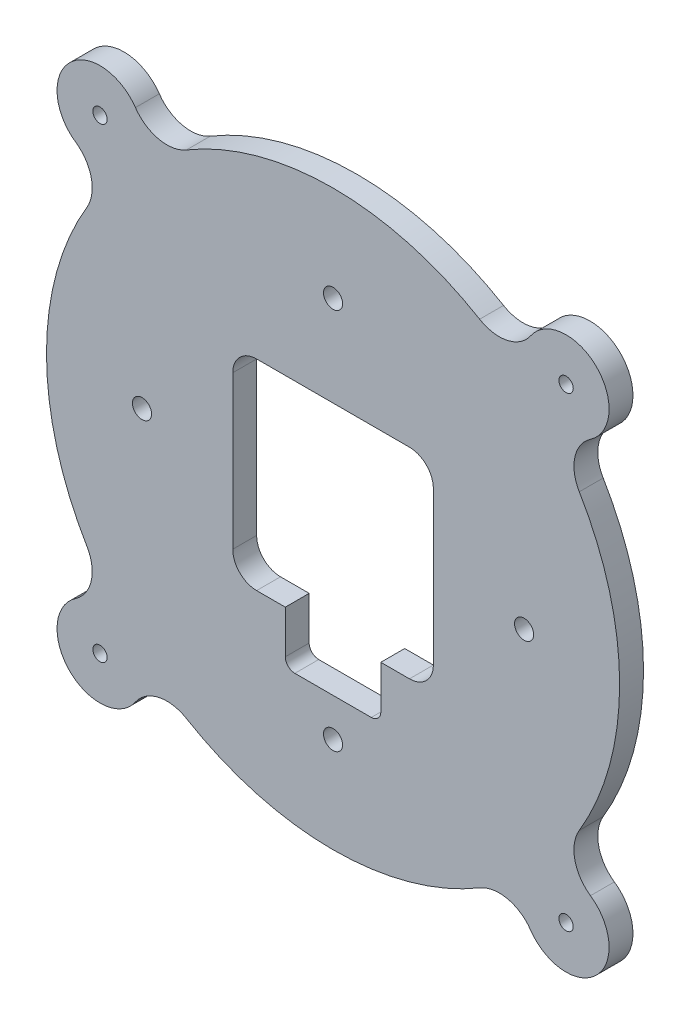
from build123d import *

# Parameters (mm, degrees)
SKETCH1_R             = 1.5
SKETCH1_R_2           = 2
BOSS_EXTRUDE1_DEPTH   = 5
BODY_MOVE_COPY1_ANGLE = 90


with BuildPart() as part:
    # Sketch1 → Boss-Extrude1 (new body)
    with BuildSketch(Plane(origin=(0, 0, 0), x_dir=(1, 0, 0), z_dir=(0, 1, 0))):
        with BuildLine():
            ThreePointArc((41.376602734, 53.892924716), (36.497232574, 50.613564399), (30.69404934, 51.554585976))
            ThreePointArc((30.69404934, 51.554585976), (0, 60), (-30.69404934, 51.554585976))
            ThreePointArc((-30.69404934, 51.554585976), (-36.497232574, 50.613564399), (-41.376602734, 53.892924716))
            ThreePointArc((-41.376602734, 53.892924716), (-55.154328933, 55.154328933), (-53.892924716, 41.376602734))
            ThreePointArc((-53.892924716, 41.376602734), (-50.613564399, 36.497232574), (-51.554585976, 30.69404934))
            ThreePointArc((-51.554585976, 30.69404934), (-60, 0), (-51.554585976, -30.69404934))
            ThreePointArc((-51.554585976, -30.69404934), (-50.613564399, -36.497232574), (-53.892924716, -41.376602734))
            ThreePointArc((-53.892924716, -41.376602734), (-55.154328933, -55.154328933), (-41.376602734, -53.892924716))
            ThreePointArc((-41.376602734, -53.892924716), (-36.497232574, -50.613564399), (-30.69404934, -51.554585976))
            ThreePointArc((-30.69404934, -51.554585976), (0, -60), (30.69404934, -51.554585976))
            ThreePointArc((30.69404934, -51.554585976), (36.497232574, -50.613564399), (41.376602734, -53.892924716))
            ThreePointArc((41.376602734, -53.892924716), (55.154328933, -55.154328933), (53.892924716, -41.376602734))
            ThreePointArc((53.892924716, -41.376602734), (50.613564399, -36.497232574), (51.554585976, -30.69404934))
            ThreePointArc((51.554585976, -30.69404934), (60, 0), (51.554585976, 30.69404934))
            ThreePointArc((51.554585976, 30.69404934), (50.613564399, 36.497232574), (53.892924716, 41.376602734))
            ThreePointArc((53.892924716, 41.376602734), (55.154328933, 55.154328933), (41.376602734, 53.892924716))
        make_face()
        with Locations((-48.790367902, -48.790367902)):
            Circle(SKETCH1_R, mode=Mode.SUBTRACT)
        with Locations((0, -40)):
            Circle(SKETCH1_R_2, mode=Mode.SUBTRACT)
        with Locations((48.790367902, -48.790367902)):
            Circle(SKETCH1_R, mode=Mode.SUBTRACT)
        with BuildLine():
            Line((16.001917019, -21), (10, -21))
            Line((10, -21), (10, -30.000108076))
            ThreePointArc((10, -30.000108076), (9.414180319, -31.414301502), (7.999957489, -32.000050194))
            Line((7.999957489, -32.000050194), (-8.000158272, -32.000050194))
            ThreePointArc((-8.000158272, -32.000050194), (-9.414280711, -31.414259919), (-10, -30.000108076))
            Line((-10, -30.000108076), (-10, -21))
            Line((-10, -21), (-16.005742178, -21))
            ThreePointArc((-16.005742178, -21), (-19.538404995, -19.534344662), (-21, -16))
            Line((-21, -16), (-21, 16))
            ThreePointArc((-21, 16), (-19.535533906, 19.535533906), (-16, 21))
            Line((-16, 21), (16, 21))
            ThreePointArc((16, 21), (19.535388079, 19.536388365), (21.000355251, 16.001561768))
            Line((21.000355251, 16.001561768), (21.000355251, -16.001561768))
            ThreePointArc((21.000355251, -16.001561768), (19.536346588, -19.535991337), (16.001917019, -21))
        make_face(mode=Mode.SUBTRACT)
        with Locations((40, 0)):
            Circle(SKETCH1_R_2, mode=Mode.SUBTRACT)
        with Locations((-40, 0)):
            Circle(SKETCH1_R_2, mode=Mode.SUBTRACT)
        with Locations((-48.790367902, 48.790367902)):
            Circle(SKETCH1_R, mode=Mode.SUBTRACT)
        with Locations((0, 40)):
            Circle(SKETCH1_R_2, mode=Mode.SUBTRACT)
        with Locations((48.790367902, 48.790367902)):
            Circle(SKETCH1_R, mode=Mode.SUBTRACT)
    extrude(amount=BOSS_EXTRUDE1_DEPTH)


with BuildPart() as part_1:
    # Body-Move/Copy1: moved
    add(part.part.rotate(Axis((0, 2.5, 0.160861545), (1, 0, 0)), BODY_MOVE_COPY1_ANGLE))


solid = part_1.part
